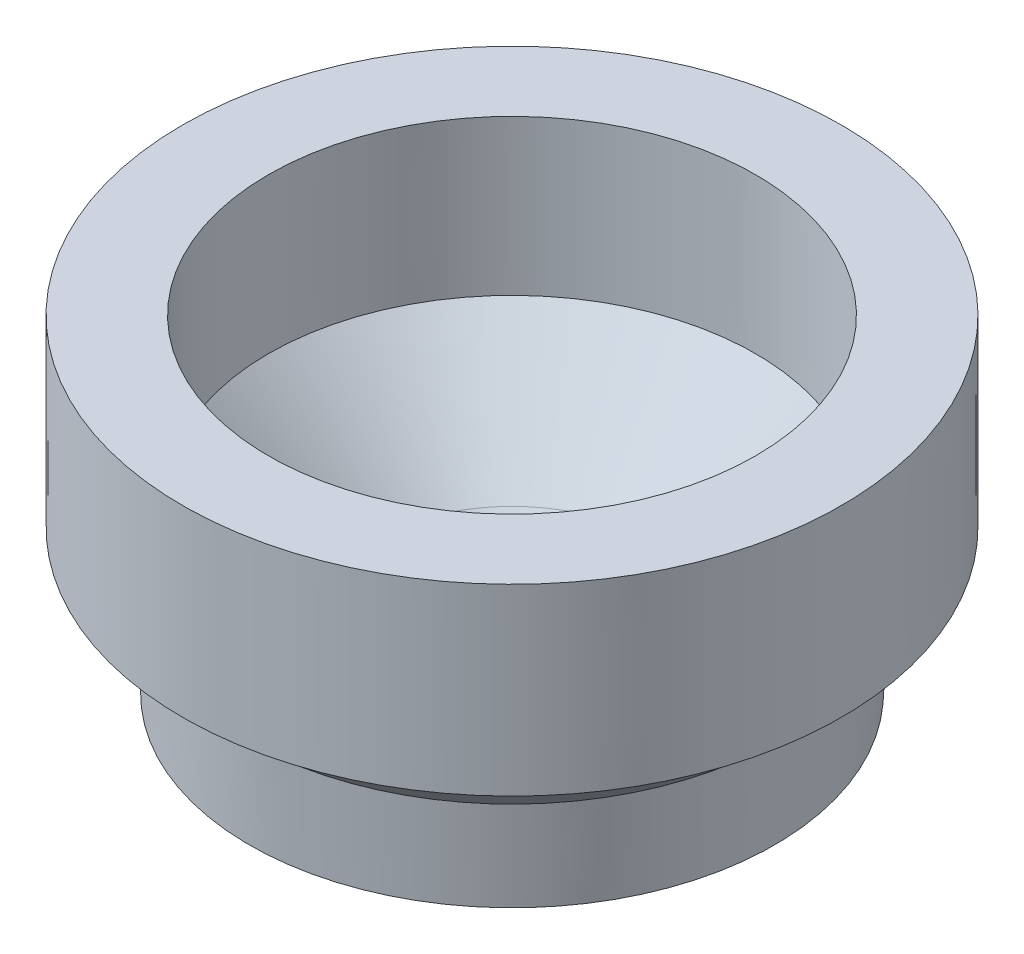
from build123d import *


with BuildPart() as part:
    # Sketch1 → Revolve1 (revolve)
    with BuildSketch(Plane.XY):
        with BuildLine():
            Line((0.000169209, 3.461128296), (0, 0))
            Line((0, 0), (10.218402158, 0))
            Line((10.218402158, 0), (12.190272224, 1.390446413))
            Line((12.190272224, 1.390446413), (12.390593979, 5.697403621))
            Line((12.390593979, 5.697403621), (15.025609693, 8.073507981))
            Line((15.025609693, 8.073507981), (15.294122949, 8.07362883))
            Line((15.294122949, 8.07362883), (15.294122949, 16.588509883))
            Line((15.294122949, 16.588509883), (11.306507295, 16.588509883))
            Line((11.306507295, 16.588509883), (11.306507295, 9.392295548))
            Line((11.306507295, 9.392295548), (6.466218888, 4.336313055))
            ThreePointArc((6.466218888, 4.336313055), (5.591548834, 3.689343395), (4.527812347, 3.461128296))
            Line((4.527812347, 3.461128296), (0.000169209, 3.461128296))
        make_face()
    revolve(axis=Axis((0.000169209, 3.461128296, 0), (-4.8888e-05, -0.999999999, 0)))


solid = part.part
